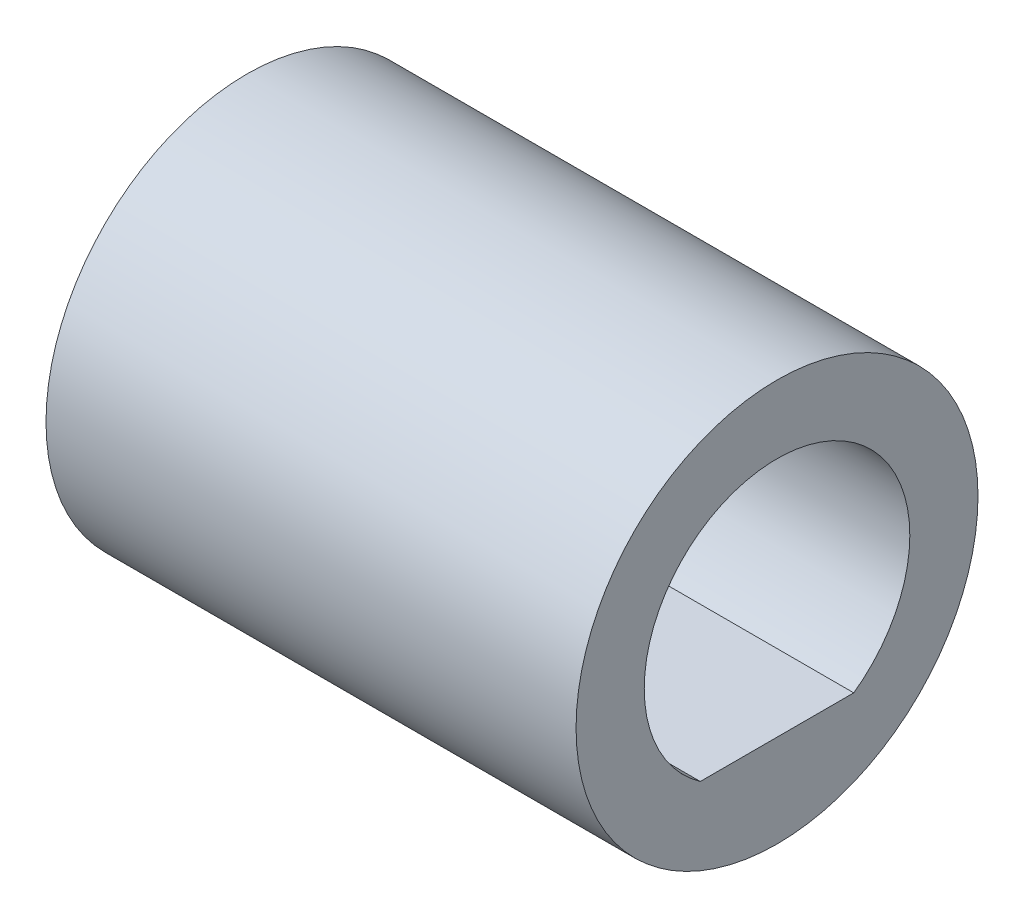
from build123d import *

# Parameters (mm, degrees)
SKETCH1_R           = 4
BOSS_EXTRUDE1_DEPTH = 10.55


with BuildPart() as part:
    # Sketch1 → Boss-Extrude1 (new body)
    with BuildSketch(Plane(origin=(0, 0, 0), x_dir=(0, 0, -1), z_dir=(1, 0, 0))):
        Circle(SKETCH1_R)
        with BuildLine():
            Line((-1.527350647, -2.157), (1.527350647, -2.157))
            ThreePointArc((1.527350647, -2.157), (0, 2.643), (-1.527350647, -2.157))
        make_face(mode=Mode.SUBTRACT)
    extrude(amount=BOSS_EXTRUDE1_DEPTH)


solid = part.part
